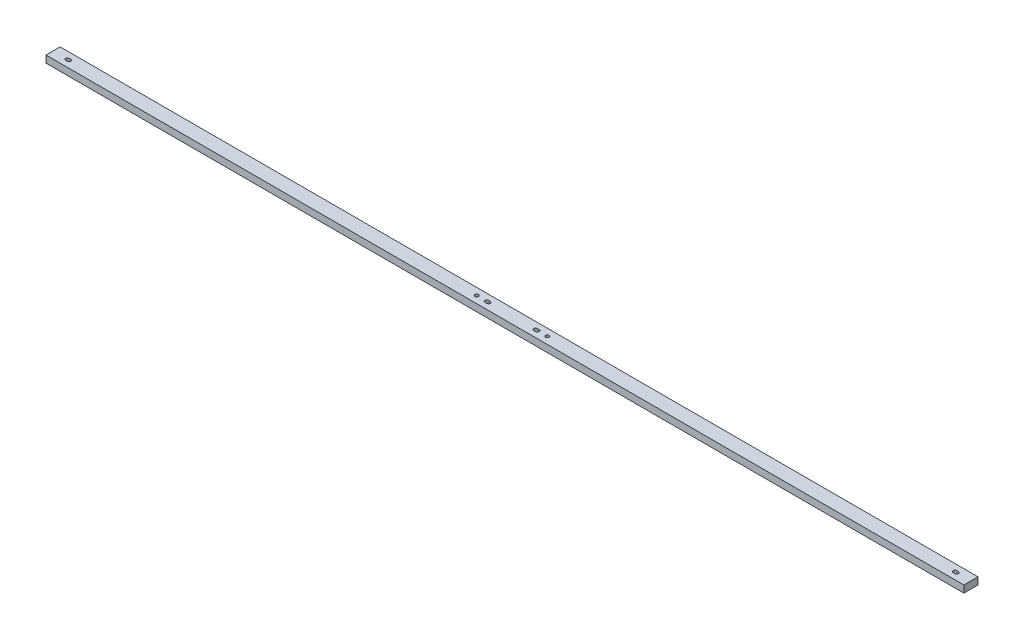
from build123d import *

# Parameters (mm, degrees)
SKETCH1_W           = 1651
SKETCH1_H           = 25.4
SKETCH1_R           = 3.175
BOSS_EXTRUDE1_DEPTH = 12.7


with BuildPart() as part:
    # Sketch1 → Boss-Extrude1 (new body)
    with BuildSketch(Plane(origin=(0, 0, 0), x_dir=(1, 0, 0), z_dir=(0, 1, 0))):
        Rectangle(SKETCH1_W, SKETCH1_H)
        with Locations((63.5, 0)):
            Circle(SKETCH1_R, mode=Mode.SUBTRACT)
        with Locations((-63.5, 0)):
            Circle(SKETCH1_R, mode=Mode.SUBTRACT)
        with BuildLine():
            Line((-799.6555, 3.175), (-796.4805, 3.175))
            ThreePointArc((-796.4805, 3.175), (-793.3055, 0), (-796.4805, -3.175))
            Line((-796.4805, -3.175), (-799.6555, -3.175))
            ThreePointArc((-799.6555, -3.175), (-802.8305, 0), (-799.6555, 3.175))
        make_face(mode=Mode.SUBTRACT)
        with BuildLine():
            Line((-45.5295, 3.175), (-42.3545, 3.175))
            ThreePointArc((-42.3545, 3.175), (-39.1795, 0), (-42.3545, -3.175))
            Line((-42.3545, -3.175), (-45.5295, -3.175))
            ThreePointArc((-45.5295, -3.175), (-48.7045, 0), (-45.5295, 3.175))
        make_face(mode=Mode.SUBTRACT)
        with BuildLine():
            Line((45.5295, 3.175), (42.3545, 3.175))
            ThreePointArc((42.3545, 3.175), (39.1795, 0), (42.3545, -3.175))
            Line((42.3545, -3.175), (45.5295, -3.175))
            ThreePointArc((45.5295, -3.175), (48.7045, 0), (45.5295, 3.175))
        make_face(mode=Mode.SUBTRACT)
        with BuildLine():
            Line((799.6555, 3.175), (796.4805, 3.175))
            ThreePointArc((796.4805, 3.175), (793.3055, 0), (796.4805, -3.175))
            Line((796.4805, -3.175), (799.6555, -3.175))
            ThreePointArc((799.6555, -3.175), (802.8305, 0), (799.6555, 3.175))
        make_face(mode=Mode.SUBTRACT)
    extrude(amount=BOSS_EXTRUDE1_DEPTH)


solid = part.part
